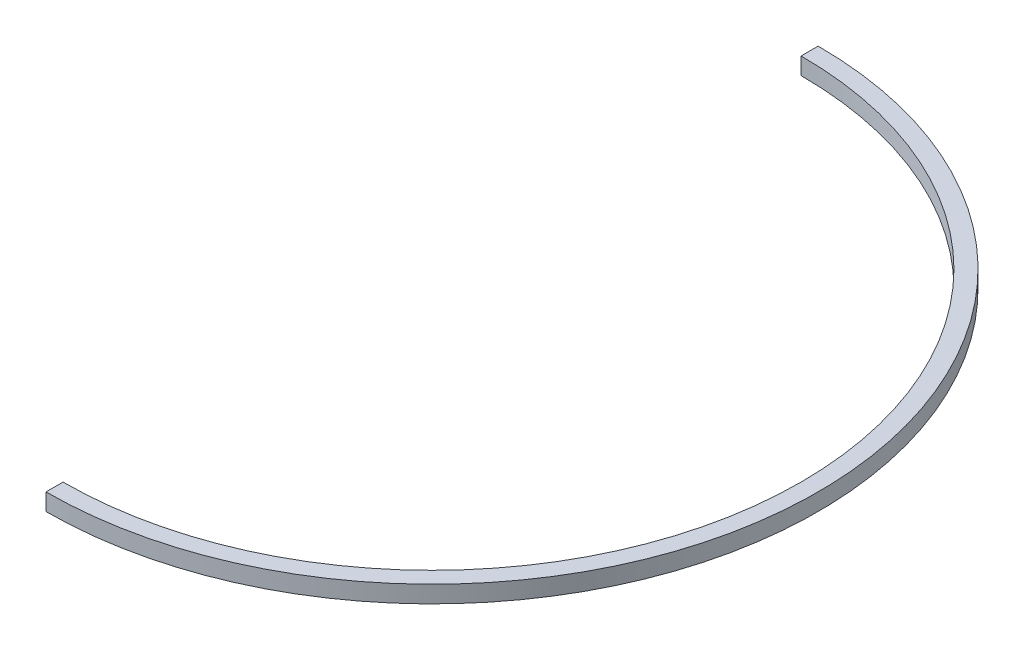
from build123d import *

# Parameters (mm, degrees)
DODANIE_WYCI_GNI_CIE1_DEPTH = 10


with BuildPart() as part:
    # Szkic1 → Dodanie-wyciągnięcie1 (new body)
    with BuildSketch(Plane(origin=(0, 0, 0), x_dir=(1, 0, 0), z_dir=(0, 1, 0))):
        with BuildLine():
            Line((0, 216.5), (0, 226.5))
            ThreePointArc((0, 226.5), (226.5, 0), (0, -226.5))
            Line((0, -226.5), (0, -216.5))
            ThreePointArc((0, -216.5), (216.5, 0), (0, 216.5))
        make_face()
    extrude(amount=DODANIE_WYCI_GNI_CIE1_DEPTH)


solid = part.part
